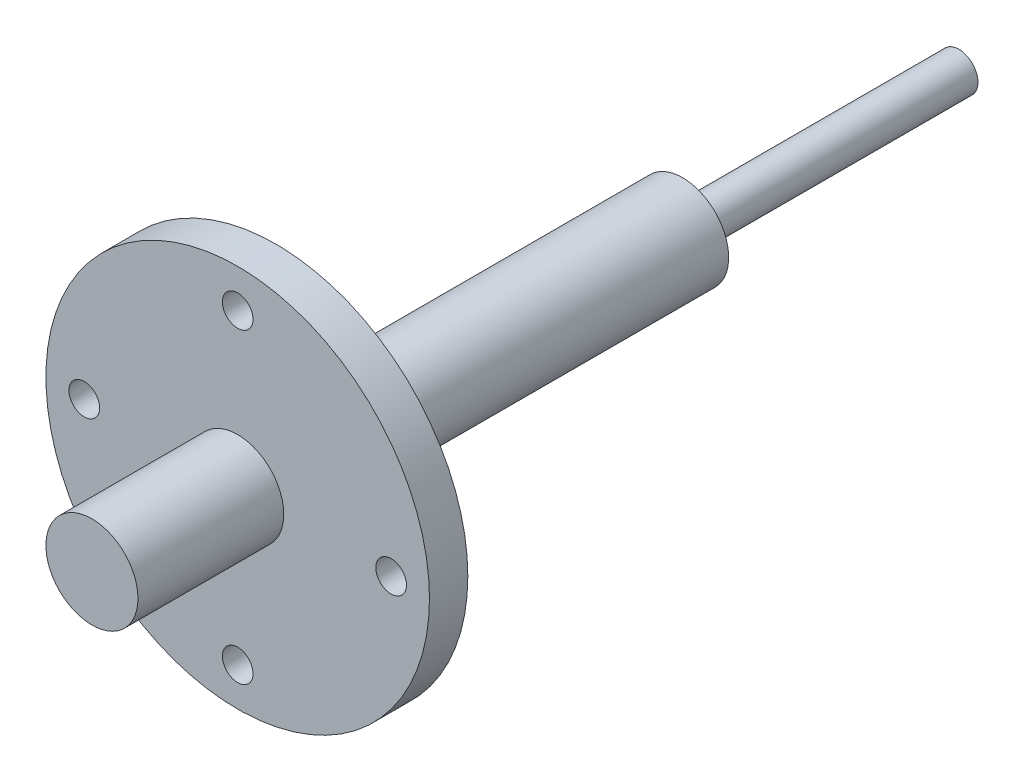
from build123d import *

# Parameters (mm, degrees)
ESQUISSE1_R                  = 25
BOSS_EXTRU_1_DEPTH           = 113
ESQUISSE2_OUTSIDE_W          = 78.66
ESQUISSE2_OUTSIDE_H          = 78.66
ESQUISSE2_OUTSIDE_R          = 6
ENL_V_MAT_EXTRU_1_DEPTH      = 19
ESQUISSE3_OUTSIDE_W          = 78.66
ESQUISSE3_OUTSIDE_H          = 78.66
ESQUISSE3_OUTSIDE_R          = 6
ENL_V_MAT_EXTRU_3_DEPTH      = 89
ENL_V_MAT_EXTRU_3_DEPTH_BACK = 89
ESQUISSE4_OUTSIDE_W          = 78.66
ESQUISSE4_OUTSIDE_H          = 78.66
ESQUISSE4_OUTSIDE_R          = 2.5
ENL_V_MAT_EXTRU_4_DEPTH      = 36
ENL_V_MAT_EXTRU_4_DEPTH_BACK = 36
ESQUISSE8_R                  = 2
ENL_V_MAT_EXTRU_5_DEPTH      = 95
R_P_TITION_CIRCULAIRE2_COUNT = 4


with BuildPart() as part:
    # Esquisse1 → Boss.-Extru.1 (new body)
    with BuildSketch(Plane.XY):
        Circle(ESQUISSE1_R)
    extrude(amount=BOSS_EXTRU_1_DEPTH)

    # Esquisse2 outside → Enl_v. mat.-Extru.1 (cut)
    with BuildSketch(Plane.XY.offset(113)):
        Rectangle(ESQUISSE2_OUTSIDE_W, ESQUISSE2_OUTSIDE_H)
        Circle(ESQUISSE2_OUTSIDE_R, mode=Mode.SUBTRACT)
    extrude(amount=-ENL_V_MAT_EXTRU_1_DEPTH, mode=Mode.SUBTRACT)

    # Esquisse3 outside → Enl_v. mat.-Extru.3 (cut, two sides)
    with BuildSketch(Plane.XY) as enl_v_mat_extru_3_sk:
        Rectangle(ESQUISSE3_OUTSIDE_W, ESQUISSE3_OUTSIDE_H)
        Circle(ESQUISSE3_OUTSIDE_R, mode=Mode.SUBTRACT)
    extrude(amount=ENL_V_MAT_EXTRU_3_DEPTH, mode=Mode.SUBTRACT)
    extrude(enl_v_mat_extru_3_sk.sketch, amount=-ENL_V_MAT_EXTRU_3_DEPTH_BACK, mode=Mode.SUBTRACT)

    # Esquisse4 outside → Enl_v. mat.-Extru.4 (cut, two sides)
    with BuildSketch(Plane(origin=(0, 0, 0), x_dir=(-1, 0, 0), z_dir=(0, 0, -1))) as enl_v_mat_extru_4_sk:
        Rectangle(ESQUISSE4_OUTSIDE_W, ESQUISSE4_OUTSIDE_H)
        with Locations(Location((0, 0, 0), (0, 0, 180))):  # turned: the seam where the file's is
            Circle(ESQUISSE4_OUTSIDE_R, mode=Mode.SUBTRACT)
    extrude(amount=ENL_V_MAT_EXTRU_4_DEPTH, mode=Mode.SUBTRACT)
    extrude(enl_v_mat_extru_4_sk.sketch, amount=-ENL_V_MAT_EXTRU_4_DEPTH_BACK, mode=Mode.SUBTRACT)

    # Esquisse8 → Enl_v. mat.-Extru.5 (cut, through all)
    with BuildSketch(Plane.XY.offset(94)):
        with Locations((0, 20)):
            Circle(ESQUISSE8_R)
    enl_v_mat_extru_5 = extrude(amount=-ENL_V_MAT_EXTRU_5_DEPTH, mode=Mode.SUBTRACT)

    # R_p_tition circulaire2: Enl_v. mat.-Extru.5 ×4 about axis
    r_p_tition_circulaire2_axis = Axis((0, 0, 0), (0, 0, 1))
    for i in range(1, R_P_TITION_CIRCULAIRE2_COUNT):
        add(enl_v_mat_extru_5.rotate(r_p_tition_circulaire2_axis, i * 360 / R_P_TITION_CIRCULAIRE2_COUNT), mode=Mode.SUBTRACT)


solid = part.part
